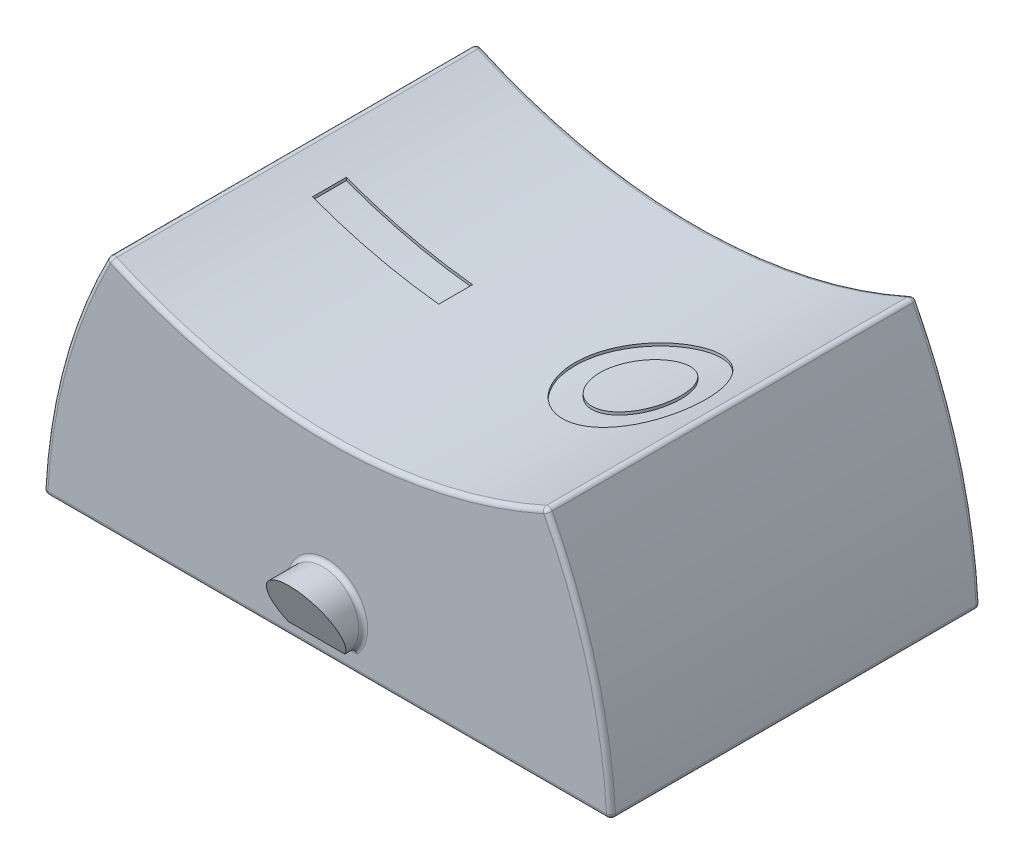
from build123d import *

# Parameters (mm, degrees)
BOSS_EXTRUDE1_DEPTH     = 5.207
SHELL1_T                = -1.27
BOSS_EXTRUDE2_REACH     = 16.757
CUT_EXTRUDE1_REACH      = 39.593
CUT_EXTRUDE1_END_RADIUS = 14.8082
CUT_EXTRUDE1_START      = -25.4
SKETCH11_R              = 1.8415
SKETCH11_R_2            = 1.143
SKETCH11_W              = 3.556
SKETCH11_H              = 0.9525
FILLET1_R               = 0.127


with BuildPart() as part:
    # Sketch1 → Boss-Extrude1 (new, symmetric)
    with BuildSketch(Plane(origin=(0, 0, 0), x_dir=(-1, 0, 0), z_dir=(0, 0, -1))):
        with BuildLine():
            Line((-8.001, 0), (8.001, 0))
            ThreePointArc((8.001, 0), (7.451075327, 3.466952212), (6.1595, 6.731))
            ThreePointArc((6.1595, 6.731), (0, 5.381540258), (-6.1595, 6.731))
            ThreePointArc((-6.1595, 6.731), (-7.451075327, 3.466952212), (-8.001, 0))
        make_face()
    extrude(amount=BOSS_EXTRUDE1_DEPTH, both=True)

    # Shell1
    shell1_openings = [part.faces().sort_by_distance(p)[0] for p in [
        (0, 0, 0),
    ]]
    offset(amount=SHELL1_T, openings=shell1_openings, kind=Kind.INTERSECTION)

    # Boss-Extrude2: up to this plane
    boss_extrude2_end = Plane(origin=(0, -1.994396708, 4.276997542), z_dir=(0, -0.4226182617407003, 0.9063077870366496))
    # Sketch5 → Boss-Extrude2 (add, up to the surface)
    with BuildSketch(Plane.XY.offset(5.207), mode=Mode.PRIVATE) as boss_extrude2_sk1:
        with BuildLine():
            Line((0.793114746, 0.635), (-0.793114746, 0.635))
            ThreePointArc((-0.793114746, 0.635), (0, 2.286), (0.793114746, 0.635))
        make_face()
    boss_extrude2_tool1 = split(extrude(boss_extrude2_sk1.sketch, amount=BOSS_EXTRUDE2_REACH, mode=Mode.PRIVATE), bisect_by=boss_extrude2_end, keep=Keep.BOTH, mode=Mode.PRIVATE)
    boss_extrude2 = boss_extrude2_tool1.solids().sort_by_distance((0, 1.387858, 5.207))[0]
    add(boss_extrude2)

    # Mirror2: Boss-Extrude2 across plane
    add(boss_extrude2.mirror(Plane.XY))

    # Cut-Extrude1: up to this cylinder (the profile starts inside it)
    cut_extrude1_end = Plane(origin=(0, 20.113540258, 0), z_dir=(0, 0, -1)) * Cylinder(CUT_EXTRUDE1_END_RADIUS, 109.8024, mode=Mode.PRIVATE)
    # Sketch11 → Cut-Extrude1 (cut, up to the surface)
    with BuildSketch(Plane.XZ.offset(CUT_EXTRUDE1_START), mode=Mode.PRIVATE) as cut_extrude1_sk1:
        with Locations(Location((3.6195, 0, 0), (0, 0, 180))):
            Circle(SKETCH11_R)
        with Locations(Location((3.6195, 0, 0), (0, 0, 180))):
            Circle(SKETCH11_R_2, mode=Mode.SUBTRACT)
    cut_extrude1_tool1 = extrude(cut_extrude1_sk1.sketch, amount=CUT_EXTRUDE1_REACH, mode=Mode.PRIVATE) & cut_extrude1_end
    add(cut_extrude1_tool1.solids().sort_by_distance((5.408915, 25.4, 0))[0], mode=Mode.SUBTRACT)
    # Sketch11 → Cut-Extrude1 (cut, up to the surface)
    with BuildSketch(Plane.XZ.offset(CUT_EXTRUDE1_START), mode=Mode.PRIVATE) as cut_extrude1_sk2:
        with Locations((-3.3655, 0)):
            Rectangle(SKETCH11_W, SKETCH11_H)
    cut_extrude1_tool2 = extrude(cut_extrude1_sk2.sketch, amount=CUT_EXTRUDE1_REACH, mode=Mode.PRIVATE) & cut_extrude1_end
    add(cut_extrude1_tool2.solids().sort_by_distance((-3.3655, 25.4, 0))[0], mode=Mode.SUBTRACT)

    # Fillet1
    fillet1_edges = [part.edges().sort_by_distance(p)[0] for p in [
        (0, 0, 5.207),
        (-7.451075327, 3.466952212, 5.207),
        (0, 4.111540258, 3.937),
        (5.535048759, 5.099305704, 0),
        (-6.360295192, 2.603068492, 3.937),
        (-5.535048759, 5.099305704, 0),
        (0, 0, 3.937),
        (-6.729437878, 0, 0),
        (6.360295192, 2.603068492, 3.937),
        (6.729437878, 0, 0),
        (0, 4.111540258, -3.937),
        (6.360295192, 2.603068492, -3.937),
        (0, 0, -3.937),
        (-6.360295192, 2.603068492, -3.937),
        (0, 2.286, 5.207),
        (0, 0.635, 5.207),
        (0, 2.286, -5.207),
        (0, 0.635, -5.207),
        (0, 5.381540258, 5.207),
        (-7.451075327, 3.466952212, -5.207),
        (0, 0, -5.207),
        (7.451075327, 3.466952212, -5.207),
        (0, 5.381540258, -5.207),
        (7.451075327, 3.466952212, 5.207),
        (-6.1595, 6.731, 0),
        (-8.001, 0, 0),
        (8.001, 0, 0),
        (6.1595, 6.731, 0),
    ]]
    fillet(fillet1_edges, radius=FILLET1_R)


solid = part.part
